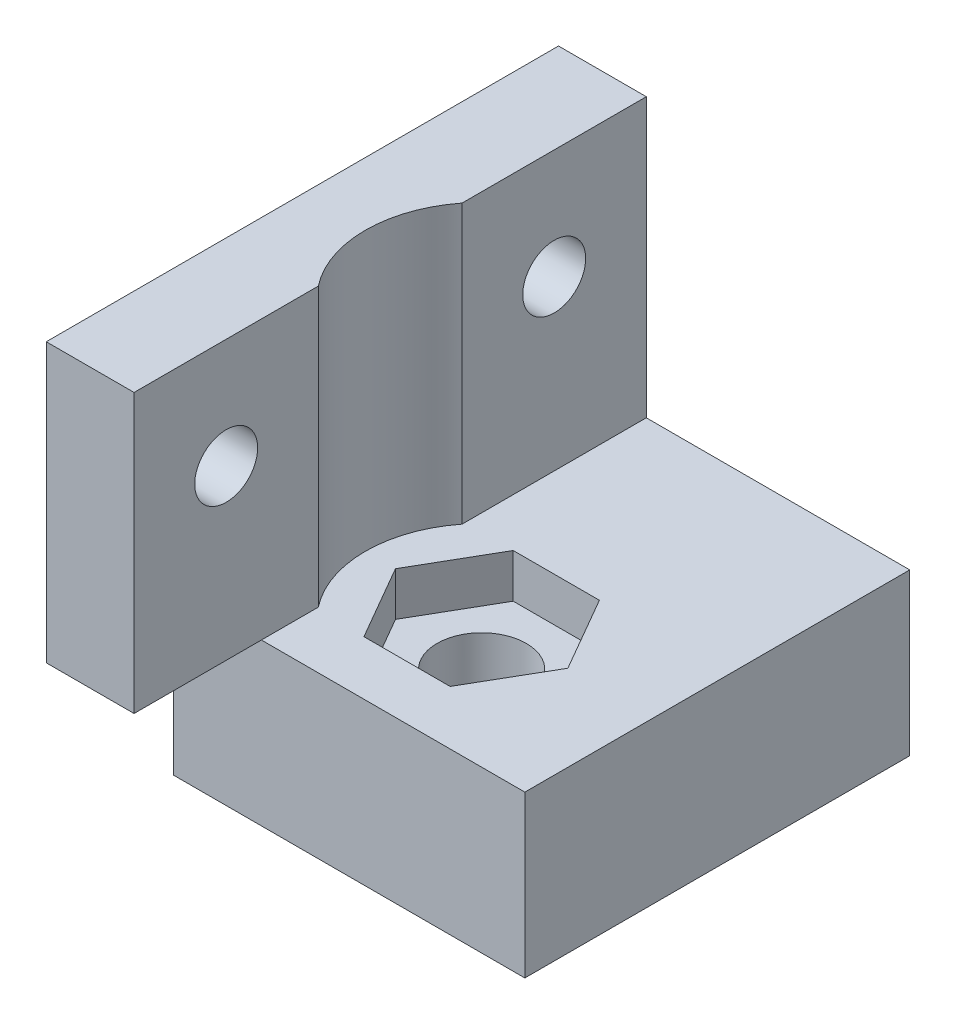
from build123d import *

# Parameters (mm, degrees)
SKETCH1_W           = 18
SKETCH1_H           = 35
SKETCH1_R           = 3.05
BOSS_EXTRUDE1_DEPTH = 11
SKETCH1_3_W         = 6
SKETCH1_3_H         = 35
BOSS_EXTRUDE2_DEPTH = 30
SKETCH2_R           = 7.949273458
CUT_EXTRUDE1_DEPTH  = 19
CUT_EXTRUDE3_DEPTH  = 3
CUT_EXTRUDE4_DEPTH  = 3
SKETCH7_R           = 2.15
CUT_EXTRUDE6_DEPTH  = 10
SKETCH8_W           = 24
SKETCH8_H           = 8.700587772
CUT_EXTRUDE7_DEPTH  = 11


with BuildPart() as part:
    # Sketch1 → Boss-Extrude1 (new body)
    with BuildSketch(Plane(origin=(0, 0, 0), x_dir=(1, 0, 0), z_dir=(0, 1, 0))):
        with Locations((12, 0)):
            Rectangle(SKETCH1_W, SKETCH1_H)
        with Locations((9.25, 0)):
            Circle(SKETCH1_R, mode=Mode.SUBTRACT)
    extrude(amount=BOSS_EXTRUDE1_DEPTH)

    # Sketch1_3 → Boss-Extrude2 (add)
    with BuildSketch(Plane(origin=(0, 0, 0), x_dir=(1, 0, 0), z_dir=(0, 1, 0))):
        Rectangle(SKETCH1_3_W, SKETCH1_3_H)
    extrude(amount=BOSS_EXTRUDE2_DEPTH)

    # Sketch2 → Cut-Extrude1 (cut)
    with BuildSketch(Plane(origin=(0, 30, 0), x_dir=(1, 0, 0), z_dir=(0, 1, 0))):
        with Locations((9.25, 0)):
            Circle(SKETCH2_R)
    extrude(amount=-CUT_EXTRUDE1_DEPTH, mode=Mode.SUBTRACT)

    # Sketch4 → Cut-Extrude3 (cut)
    with BuildSketch(Plane(origin=(0, 11, 0), x_dir=(1, 0, 0), z_dir=(0, 1, 0))):
        Polygon((15.138972746, 0), (12.194486373, 5.1), (6.305513627, 5.1), (3.361027254, 0), (6.305513627, -5.1), (12.194486373, -5.1), align=None)
    extrude(amount=-CUT_EXTRUDE3_DEPTH, mode=Mode.SUBTRACT)

    # Sketch5 → Cut-Extrude4 (cut)
    with BuildSketch(Plane.XZ):
        Polygon((3.361027254, 0), (6.305513627, -5.1), (12.194486373, -5.1), (15.138972746, 0), (12.194486373, 5.1), (6.305513627, 5.1), align=None)
    extrude(amount=-CUT_EXTRUDE4_DEPTH, mode=Mode.SUBTRACT)

    # Sketch7 → Cut-Extrude6 (cut)
    with BuildSketch(Plane(origin=(3, 0, 0), x_dir=(0, 0, -1), z_dir=(1, 0, 0))):
        with Locations((-11.206035856, 22.5)):
            Circle(SKETCH7_R)
        with Locations((11.206035856, 22.5)):
            Circle(SKETCH7_R)
    extrude(amount=-CUT_EXTRUDE6_DEPTH, mode=Mode.SUBTRACT)

    # Sketch8 → Cut-Extrude7 (cut)
    with BuildSketch(Plane.XZ):
        with Locations((9, 13.149706114)):
            Rectangle(SKETCH8_W, SKETCH8_H)
    extrude(amount=-CUT_EXTRUDE7_DEPTH, mode=Mode.SUBTRACT)


solid = part.part
